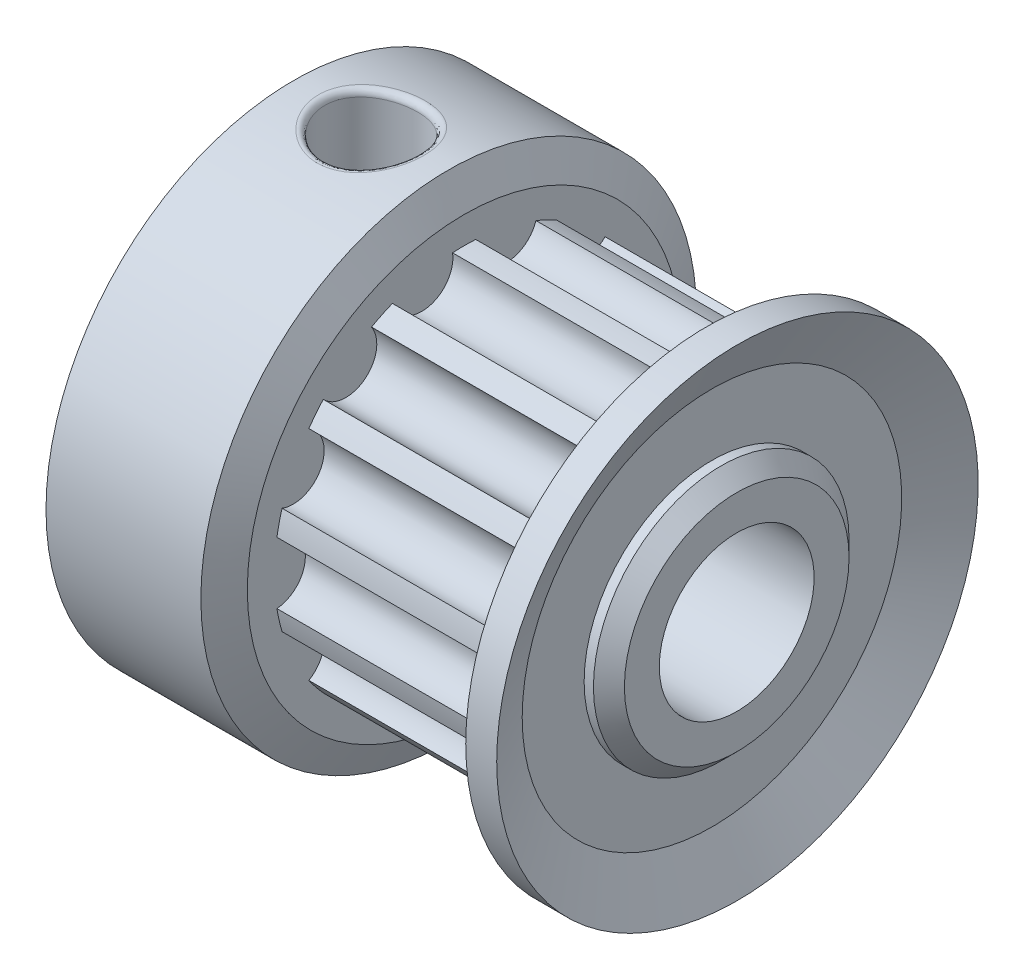
from build123d import *

# Parameters (mm, degrees)
IZIM2_R               = 2.5
KES_EKSTR_ZYON1_DEPTH = 15.822873016
IZIM3_R               = 1
KES_EKSTR_ZYON3_DEPTH = 7
IZIM4_R               = 1.5
KES_EKSTR_ZYON4_DEPTH = 27
RADYUS1_R             = 0.2


with BuildPart() as part:
    # Çizim1 → Döndür1 (revolve)
    with BuildSketch(Plane.XY):
        with BuildLine():
            Line((0, 7), (0, 3.9))
            ThreePointArc((0, 3.9), (0.029289322, 3.829289322), (0.1, 3.8))
            Line((0.1, 3.8), (0.3, 3.8))
            Line((0.3, 3.8), (0, 3.5))
            Line((0, 3.5), (0, 0))
            Line((0, 0), (14.8, 0))
            Line((14.8, 0), (14.8, 1.887324991))
            Line((14.8, 1.887324991), (14.8, 3.6263585))
            Line((14.8, 3.6263585), (14.3, 4.1263585))
            Line((14.3, 4.1263585), (14, 4.1263585))
            Line((14, 4.1263585), (14, 6.1263585))
            Line((14, 6.1263585), (14.822873016, 7.772104531))
            Line((14.822873016, 7.772104531), (13.822873016, 7.772104531))
            Line((13.822873016, 7.772104531), (13, 6.1263585))
            Line((13, 6.1263585), (6, 6.1263585))
            Line((6, 6.1263585), (6, 7))
            Line((6, 7), (5.5, 8))
            Line((5.5, 8), (0.5, 8))
            Line((0.5, 8), (0, 7))
        make_face()
    revolve(axis=Axis((0, 0, 0), (1, 0, 0)))

    # Çizim2 → Kes-Ekstrüzyon1 (cut, through all)
    with BuildSketch(Plane.ZY):
        Circle(IZIM2_R)
    extrude(amount=-KES_EKSTR_ZYON1_DEPTH, mode=Mode.SUBTRACT)

    # Çizim3 → Kes-Ekstrüzyon3 (cut)
    with BuildSketch(Plane(origin=(6, 0, 0), x_dir=(0, 0, -1), z_dir=(1, 0, 0))):
        with Locations((6.1263585, 0)):
            Circle(IZIM3_R)
        with Locations((5.519658282, -2.658127333)):
            Circle(IZIM3_R)
        with Locations((3.819722047, -4.789779948)):
            Circle(IZIM3_R)
        with Locations((1.363243015, -5.972757901)):
            Circle(IZIM3_R)
        with Locations((-1.363243015, -5.972757901)):
            Circle(IZIM3_R)
        with Locations((-3.819722047, -4.789779948)):
            Circle(IZIM3_R)
        with Locations((-5.519658282, -2.658127333)):
            Circle(IZIM3_R)
        with Locations((-6.1263585, 0)):
            Circle(IZIM3_R)
        with Locations((-5.519658282, 2.658127333)):
            Circle(IZIM3_R)
        with Locations((-3.819722047, 4.789779948)):
            Circle(IZIM3_R)
        with Locations((-1.363243015, 5.972757901)):
            Circle(IZIM3_R)
        with Locations((1.363243015, 5.972757901)):
            Circle(IZIM3_R)
        with Locations((3.819722047, 4.789779948)):
            Circle(IZIM3_R)
        with Locations((5.519658282, 2.658127333)):
            Circle(IZIM3_R)
    extrude(amount=KES_EKSTR_ZYON3_DEPTH, mode=Mode.SUBTRACT)

    # Çizim4 → Kes-Ekstrüzyon4 (cut)
    with BuildSketch(Plane(origin=(0, 0, 0), x_dir=(1, 0, 0), z_dir=(0, 1, 0))):
        with Locations((3, 0)):
            Circle(IZIM4_R)
    extrude(amount=KES_EKSTR_ZYON4_DEPTH, mode=Mode.SUBTRACT)

    # Radyus1
    radyus1_edges = [part.edges().sort_by_distance(p)[0] for p in [
        (3, 7.858116823, 1.5),
        (1.5, 2.5, 0),
    ]]
    fillet(radyus1_edges, radius=RADYUS1_R)


solid = part.part
